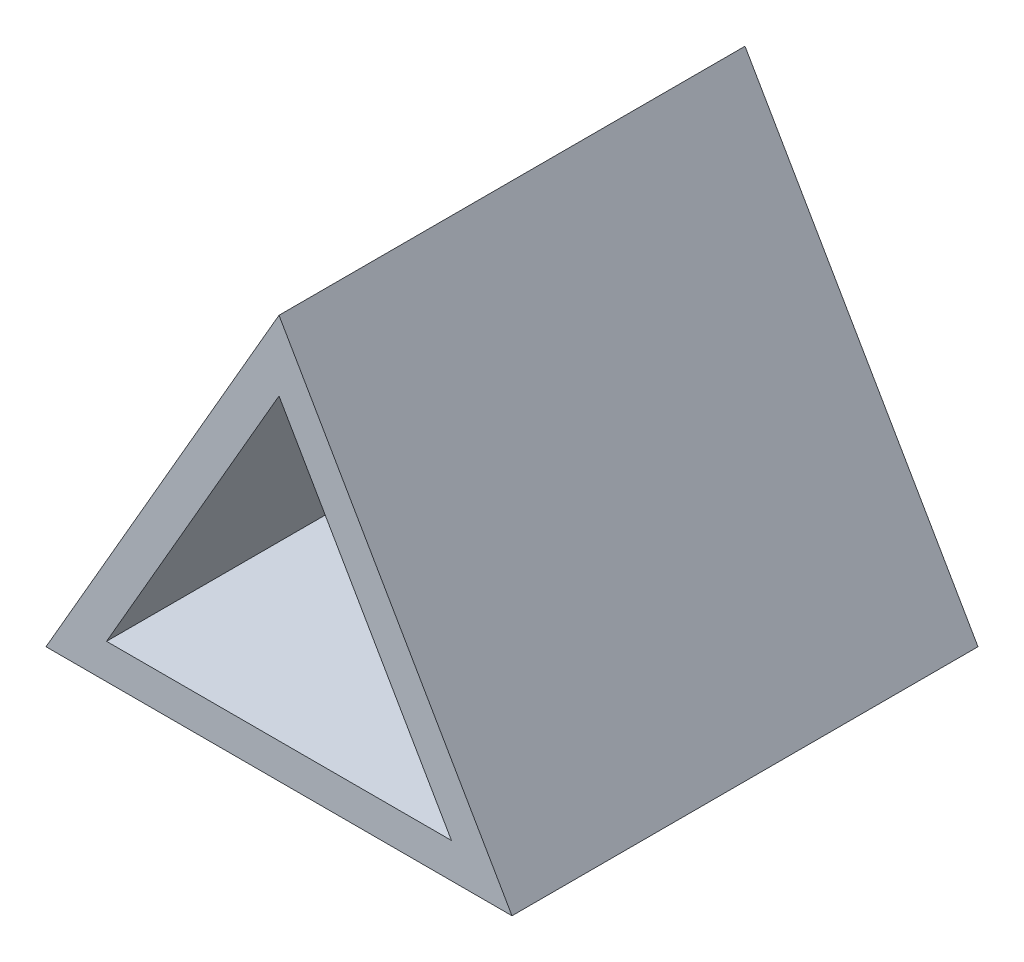
from build123d import *

# Parameters (mm, degrees)
EXTRUDE_1_DEPTH     = 40
CUT_EXTRUDE_1_DEPTH = 37


with BuildPart() as part:
    # 草图1 → 凸台-拉伸1 (new body)
    with BuildSketch(Plane.XY):
        Polygon((9.563382094, 43.508615242), (-10.436617906, 8.86759909), (29.563382094, 8.86759909), align=None)
    extrude(amount=EXTRUDE_1_DEPTH)

    # 草图2 → 切除-拉伸1 (cut)
    with BuildSketch(Plane.XY.offset(40)):
        Polygon((9.563382094, 37.508615242), (-5.240465483, 11.86759909), (24.367229672, 11.86759909), align=None)
    extrude(amount=-CUT_EXTRUDE_1_DEPTH, mode=Mode.SUBTRACT)


solid = part.part
